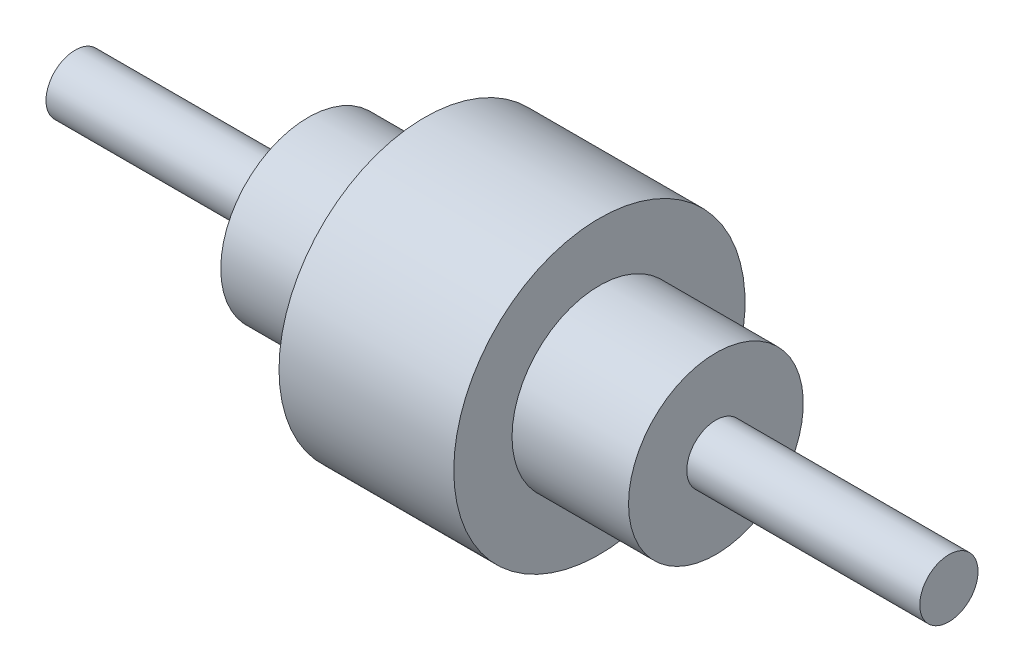
from build123d import *


with BuildPart() as part:
    # Sketch1 → Revolve4 (revolve)
    with BuildSketch(Plane.XY, mode=Mode.PRIVATE) as revolve4_sk:
        Polygon((0, 0), (0, 254), (2032, 254), (2032, 762), (3048, 762), (3048, 1270), (4572, 1270), (4572, 762), (5588, 762), (5588, 254), (7620, 254), (7620, 0), align=None)
    revolve(revolve4_sk.sketch.rotate(Axis((0, 0, 0), (1, 0, 0)), 90), axis=Axis((0, 0, 0), (1, 0, 0)))  # turned: the seam where the file's is


solid = part.part
